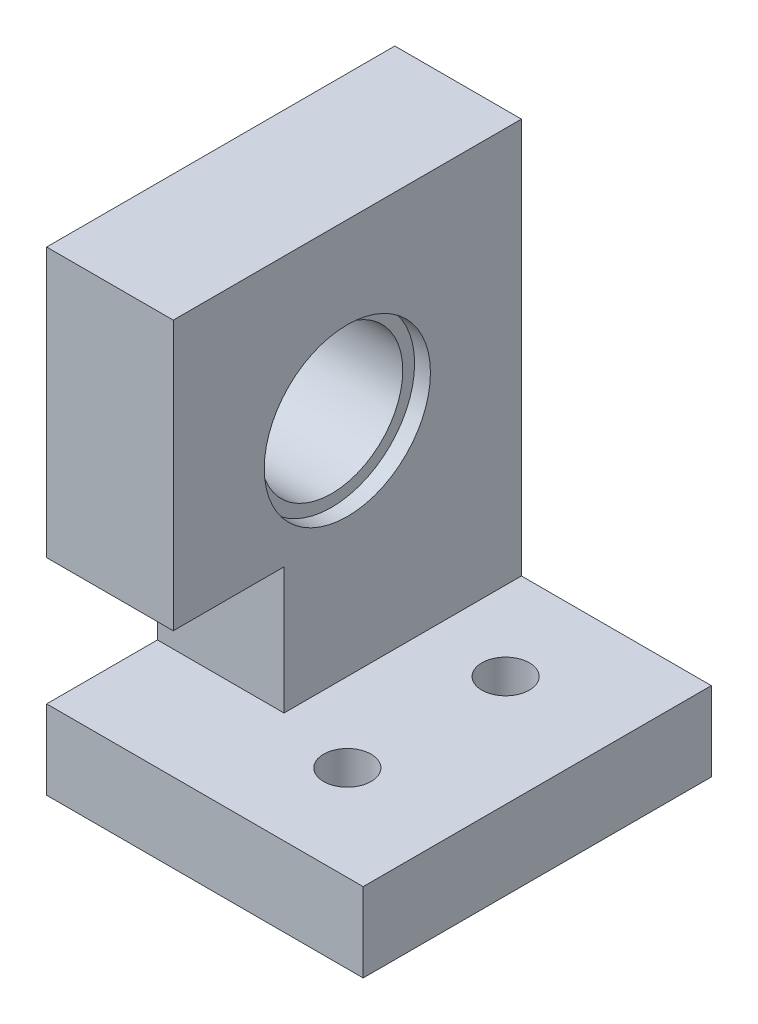
from build123d import *

# Parameters (mm, degrees)
SKETCH_1_W             = 22
SKETCH_1_H             = 30
EXTRUDE_1_DEPTH        = 8
SKETCH_2_R             = 4.5
CUT_EXTRUDE_1_DEPTH    = 9
SKETCH_3_W             = 7
SKETCH_3_H             = 8
CUT_EXTRUDE_2_DEPTH    = 9
SKETCH_4_R             = 5.25
CUT_EXTRUDE_3_DEPTH    = 1
SKETCH_5_R             = 5.25
CUT_EXTRUDE_4_DEPTH    = 1
SKETCH_6_W             = 22
SKETCH_6_H             = 5
EXTRUDE_2_DEPTH        = 12
CUT_EXTRUDE_5_DEPTH    = 2.5
PATTERN_LINEAR_1_COUNT = 2
PATTERN_LINEAR_1_PITCH = 10
SKETCH_8_R             = 1.5
CUT_EXTRUDE_6_DEPTH    = 28.5
PATTERN_LINEAR_2_COUNT = 2
PATTERN_LINEAR_2_PITCH = 10


with BuildPart() as part:
    # 草图1 → 凸台-拉伸1 (new body)
    with BuildSketch(Plane(origin=(0, 0, 0), x_dir=(0, 0, -1), z_dir=(1, 0, 0))):
        Rectangle(SKETCH_1_W, SKETCH_1_H)
    extrude(amount=EXTRUDE_1_DEPTH)

    # 草图2 → 切除-拉伸1 (cut, through all)
    with BuildSketch(Plane.ZY):
        with Locations((0, 4)):
            Circle(SKETCH_2_R)
    extrude(amount=-CUT_EXTRUDE_1_DEPTH, mode=Mode.SUBTRACT)

    # 草图3 → 切除-拉伸2 (cut, through all)
    with BuildSketch(Plane.ZY):
        with Locations((7.5, -6)):
            Rectangle(SKETCH_3_W, SKETCH_3_H)
    extrude(amount=-CUT_EXTRUDE_2_DEPTH, mode=Mode.SUBTRACT)

    # 草图4 → 切除-拉伸3 (cut)
    with BuildSketch(Plane.ZY):
        with Locations((0, 4)):
            Circle(SKETCH_4_R)
    extrude(amount=-CUT_EXTRUDE_3_DEPTH, mode=Mode.SUBTRACT)

    # 草图5 → 切除-拉伸4 (cut)
    with BuildSketch(Plane(origin=(8, 0, 0), x_dir=(0, 0, -1), z_dir=(1, 0, 0))):
        with Locations((0, 4)):
            Circle(SKETCH_5_R)
    extrude(amount=-CUT_EXTRUDE_4_DEPTH, mode=Mode.SUBTRACT)

    # 草图6 → 凸台-拉伸2 (add)
    with BuildSketch(Plane(origin=(8, 0, 0), x_dir=(0, 0, -1), z_dir=(1, 0, 0))):
        with Locations((0, -12.5)):
            Rectangle(SKETCH_6_W, SKETCH_6_H)
    extrude(amount=EXTRUDE_2_DEPTH)

    # 草图7 → 切除-拉伸5 (cut)
    with BuildSketch(Plane.XZ.offset(15)):
        Polygon((9.8, -5), (11.4, -7.771281292), (14.6, -7.771281292), (16.2, -5), (14.6, -2.228718708), (11.4, -2.228718708), align=None)
    cut_extrude_5 = extrude(amount=-CUT_EXTRUDE_5_DEPTH, mode=Mode.SUBTRACT)

    # 阵列(线性)1: 切除-拉伸5 ×2
    with Locations(*[(0, 0, i * PATTERN_LINEAR_1_PITCH) for i in range(1, PATTERN_LINEAR_1_COUNT)]):
        add(cut_extrude_5, mode=Mode.SUBTRACT)

    # 草图8 → 切除-拉伸6 (cut, through all)
    with BuildSketch(Plane.XZ.offset(12.5)):
        with Locations((13, 5)):
            Circle(SKETCH_8_R)
    cut_extrude_6 = extrude(amount=-CUT_EXTRUDE_6_DEPTH, mode=Mode.SUBTRACT)

    # 阵列(线性)2: 切除-拉伸6 ×2
    with Locations(*[(0, 0, -i * PATTERN_LINEAR_2_PITCH) for i in range(1, PATTERN_LINEAR_2_COUNT)]):
        add(cut_extrude_6, mode=Mode.SUBTRACT)


solid = part.part
